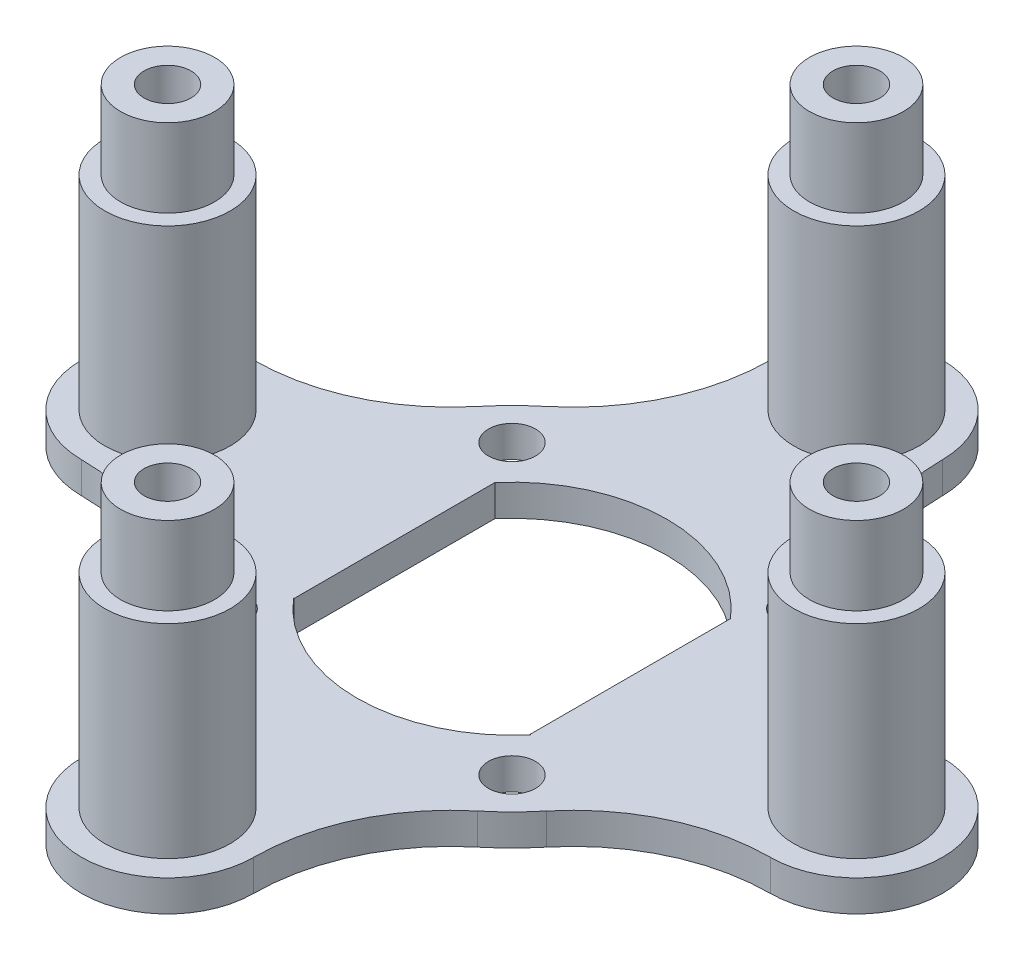
from build123d import *

# Parameters (mm, degrees)
SKETCH2_R           = 1.5
BOSS_EXTRUDE1_DEPTH = 2
SKETCH2_4_R         = 4
SKETCH2_4_R_2       = 1.5
BOSS_EXTRUDE2_DEPTH = 20
CUT_EXTRUDE1_START  = 20
SKETCH2_5_R         = 4
SKETCH2_5_R_2       = 3
CUT_EXTRUDE1_DEPTH  = 5


with BuildPart() as part:
    # Sketch2 → Boss-Extrude1 (new body)
    with BuildSketch(Plane(origin=(0, 0, 0), x_dir=(1, 0, 0), z_dir=(0, 1, 0))):
        with BuildLine():
            ThreePointArc((22, -5.5), (27.5, 0), (22, 5.5))
            ThreePointArc((22, 5.5), (16.628166969, 6.705737819), (12.286949473, 10.091623885))
            ThreePointArc((12.286949473, 10.091623885), (11.242997821, 11.242997821), (10.091623885, 12.286949473))
            ThreePointArc((10.091623885, 12.286949473), (6.705737819, 16.628166969), (5.5, 22))
            ThreePointArc((5.5, 22), (0, 27.5), (-5.5, 22))
            ThreePointArc((-5.5, 22), (-6.705737819, 16.628166969), (-10.091623885, 12.286949473))
            ThreePointArc((-10.091623885, 12.286949473), (-11.242997821, 11.242997821), (-12.286949473, 10.091623885))
            ThreePointArc((-12.286949473, 10.091623885), (-16.628166969, 6.705737819), (-22, 5.5))
            ThreePointArc((-22, 5.5), (-27.5, 0), (-22, -5.5))
            ThreePointArc((-22, -5.5), (-16.628166969, -6.705737819), (-12.286949473, -10.091623885))
            ThreePointArc((-12.286949473, -10.091623885), (-11.242997821, -11.242997821), (-10.091623885, -12.286949473))
            ThreePointArc((-10.091623885, -12.286949473), (-6.705737819, -16.628166969), (-5.5, -22))
            ThreePointArc((-5.5, -22), (0, -27.5), (5.5, -22))
            ThreePointArc((5.5, -22), (6.705737819, -16.628166969), (10.091623885, -12.286949473))
            ThreePointArc((10.091623885, -12.286949473), (11.242997821, -11.242997821), (12.286949473, -10.091623885))
            ThreePointArc((12.286949473, -10.091623885), (16.628166969, -6.705737819), (22, -5.5))
        make_face()
        with Locations(Location((-22, 0, 0), (0, 0, 270))):
            Circle(SKETCH2_R, mode=Mode.SUBTRACT)
        with Locations(Location((-9.192388155, -9.192388155, 0), (0, 0, 270))):
            Circle(SKETCH2_R, mode=Mode.SUBTRACT)
        with BuildLine():
            Line((7.526291329, 6.431558041), (7.526291329, 0))
            Line((7.526291329, 0), (7.526291329, -6.388653952))
            Line((7.526291329, -6.388653952), (7.562744256, -6.388653952))
            ThreePointArc((7.562744256, -6.388653952), (-1e-09, -9.9), (-7.562744258, -6.38865395))
            Line((-7.562744258, -6.38865395), (-7.526291329, -6.388653952))
            Line((-7.526291329, -6.388653952), (-7.526291329, 6.431558041))
            ThreePointArc((-7.526291329, 6.431558041), (0, 9.9), (7.526291329, 6.431558041))
        make_face(mode=Mode.SUBTRACT)
        with Locations(Location((0, -22, 0), (0, 0, 270))):
            Circle(SKETCH2_R, mode=Mode.SUBTRACT)
        with Locations(Location((9.192388155, -9.192388155, 0), (0, 0, 270))):
            Circle(SKETCH2_R, mode=Mode.SUBTRACT)
        with Locations(Location((22, 0, 0), (0, 0, 270))):
            Circle(SKETCH2_R, mode=Mode.SUBTRACT)
        with Locations(Location((-9.192388155, 9.192388155, 0), (0, 0, 270))):
            Circle(SKETCH2_R, mode=Mode.SUBTRACT)
        with Locations(Location((9.192388155, 9.192388155, 0), (0, 0, 270))):
            Circle(SKETCH2_R, mode=Mode.SUBTRACT)
        with Locations(Location((0, 22, 0), (0, 0, 270))):
            Circle(SKETCH2_R, mode=Mode.SUBTRACT)
    extrude(amount=BOSS_EXTRUDE1_DEPTH)

    # Sketch2_4 → Boss-Extrude2 (add)
    with BuildSketch(Plane(origin=(0, 0, 0), x_dir=(1, 0, 0), z_dir=(0, 1, 0))):
        with Locations(Location((22, 0, 0), (0, 0, 270))):
            Circle(SKETCH2_4_R)
        with Locations(Location((22, 0, 0), (0, 0, 270))):
            Circle(SKETCH2_4_R_2, mode=Mode.SUBTRACT)
        with Locations(Location((0, -22, 0), (0, 0, 270))):
            Circle(SKETCH2_4_R)
        with Locations(Location((0, -22, 0), (0, 0, 270))):
            Circle(SKETCH2_4_R_2, mode=Mode.SUBTRACT)
        with Locations(Location((-22, 0, 0), (0, 0, 270))):
            Circle(SKETCH2_4_R)
        with Locations(Location((-22, 0, 0), (0, 0, 270))):
            Circle(SKETCH2_4_R_2, mode=Mode.SUBTRACT)
        with Locations(Location((0, 22, 0), (0, 0, 270))):
            Circle(SKETCH2_4_R)
        with Locations(Location((0, 22, 0), (0, 0, 270))):
            Circle(SKETCH2_4_R_2, mode=Mode.SUBTRACT)
    extrude(amount=BOSS_EXTRUDE2_DEPTH)

    # Sketch2_5 → Cut-Extrude1 (cut)
    with BuildSketch(Plane(origin=(0, 0, 0), x_dir=(1, 0, 0), z_dir=(0, 1, 0)).offset(CUT_EXTRUDE1_START)):
        with Locations(Location((-22, 0, 0), (0, 0, 270))):
            Circle(SKETCH2_5_R)
        with Locations(Location((-22, 0, 0), (0, 0, 270))):
            Circle(SKETCH2_5_R_2, mode=Mode.SUBTRACT)
        with Locations(Location((0, 22, 0), (0, 0, 270))):
            Circle(SKETCH2_5_R)
        with Locations(Location((0, 22, 0), (0, 0, 270))):
            Circle(SKETCH2_5_R_2, mode=Mode.SUBTRACT)
        with BuildLine():
            ThreePointArc((19, 0), (22, 3), (25, 0))
            Line((25, 0), (26, 0))
            ThreePointArc((26, 0), (22, 4), (18, 0))
            Line((18, 0), (19, 0))
        make_face()
        with BuildLine():
            Line((26, 0), (25, 0))
            ThreePointArc((25, 0), (22, -3), (19, 0))
            Line((19, 0), (18, 0))
            ThreePointArc((18, 0), (22, -4), (26, 0))
        make_face()
        with Locations(Location((0, -22, 0), (0, 0, 270))):
            Circle(SKETCH2_5_R)
        with Locations(Location((0, -22, 0), (0, 0, 270))):
            Circle(SKETCH2_5_R_2, mode=Mode.SUBTRACT)
    extrude(amount=-CUT_EXTRUDE1_DEPTH, mode=Mode.SUBTRACT)


solid = part.part
